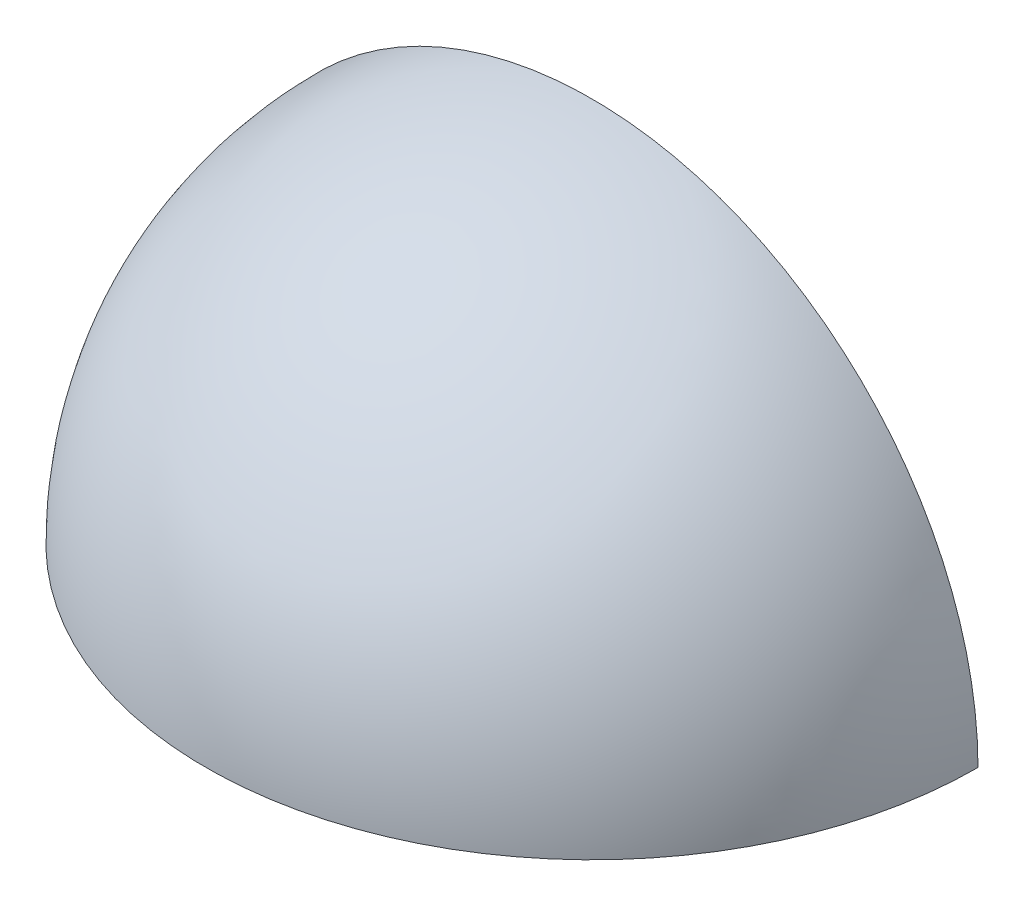
from build123d import *

# Parameters (mm, degrees)
REVOLUCI_N1_ANGLE = 90


with BuildPart() as part:
    # Croquis1 → Revolución1 (revolve)
    with BuildSketch(Plane.XY):
        with BuildLine():
            Line((-30, 0), (-28.5, 0))
            ThreePointArc((-28.5, 0), (0, 28.5), (28.5, 0))
            Line((28.5, 0), (30, 0))
            ThreePointArc((30, 0), (0, 30), (-30, 0))
        make_face()
    revolve(axis=Axis((-30, 0, 0), (1, 0, 0)), revolution_arc=REVOLUCI_N1_ANGLE)


solid = part.part
